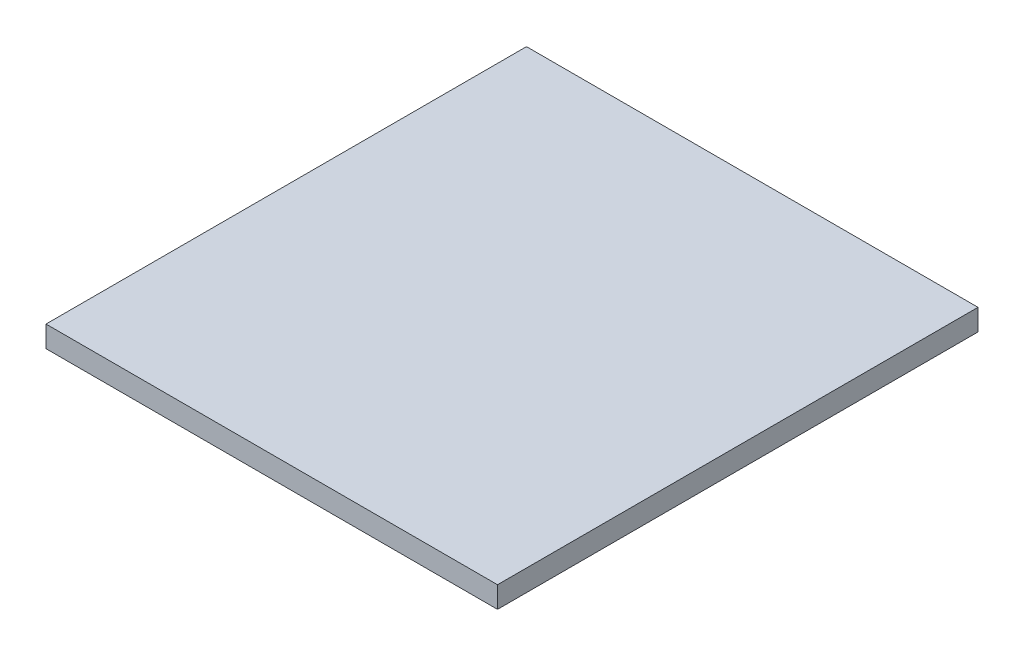
from build123d import *

# Parameters (mm, degrees)
SKETCH1_W           = 422.86
SKETCH1_H           = 450
BOSS_EXTRUDE1_DEPTH = 20


with BuildPart() as part:
    # Sketch1 → Boss-Extrude1 (new body)
    with BuildSketch(Plane(origin=(0, 0, 0), x_dir=(1, 0, 0), z_dir=(0, 1, 0))):
        Rectangle(SKETCH1_W, SKETCH1_H)
    extrude(amount=BOSS_EXTRUDE1_DEPTH)


solid = part.part
